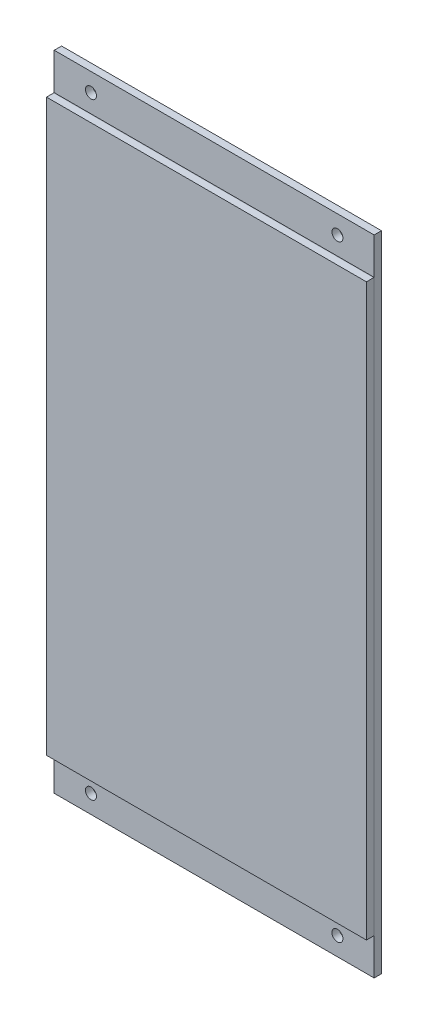
from build123d import *

# Parameters (mm, degrees)
SKETCH1_W           = 87.1
SKETCH1_H           = 155.2
BOSS_EXTRUDE1_DEPTH = 2
SKETCH3_W           = 87.1
SKETCH3_H           = 155.2
BOSS_EXTRUDE3_DEPTH = 0.1
SKETCH4_W           = 87.1
SKETCH4_H           = 175.2
BOSS_EXTRUDE4_DEPTH = 2
SKETCH5_R           = 1.5
CUT_EXTRUDE1_DEPTH  = 2


with BuildPart() as part:
    # Sketch1 → Boss-Extrude1 (new body)
    with BuildSketch(Plane.XY):
        with Locations((27.028431373, -50.132892157)):
            Rectangle(SKETCH1_W, SKETCH1_H)
    extrude(amount=BOSS_EXTRUDE1_DEPTH)


with BuildPart() as body_2:
    # Sketch3 → Boss-Extrude3 (new body)
    with BuildSketch(Plane(origin=(0, 0, 0), x_dir=(-1, 0, 0), z_dir=(0, 0, -1))):
        with Locations((-27.028431373, -50.132892157)):
            Rectangle(SKETCH3_W, SKETCH3_H)
    extrude(amount=BOSS_EXTRUDE3_DEPTH)


with BuildPart() as body_3:
    # Sketch4 → Boss-Extrude4 (new body)
    with BuildSketch(Plane(origin=(0, 0, -0.1), x_dir=(-1, 0, 0), z_dir=(0, 0, -1))):
        with Locations((-27.028431373, -50.132892157)):
            Rectangle(SKETCH4_W, SKETCH4_H)
    extrude(amount=BOSS_EXTRUDE4_DEPTH)

    # Sketch5 → Cut-Extrude1 (cut)
    with BuildSketch(Plane.XY.offset(-0.1)):
        with Locations((-6.521568627, 32.467107843)):
            Circle(SKETCH5_R)
        with Locations((60.578431373, 32.467107843)):
            Circle(SKETCH5_R)
        with Locations((-6.521568627, -132.732892157)):
            Circle(SKETCH5_R)
        with Locations((60.578431373, -132.732892157)):
            Circle(SKETCH5_R)
    extrude(amount=-CUT_EXTRUDE1_DEPTH, mode=Mode.SUBTRACT)


solid = Compound([part.part, body_2.part, body_3.part])
